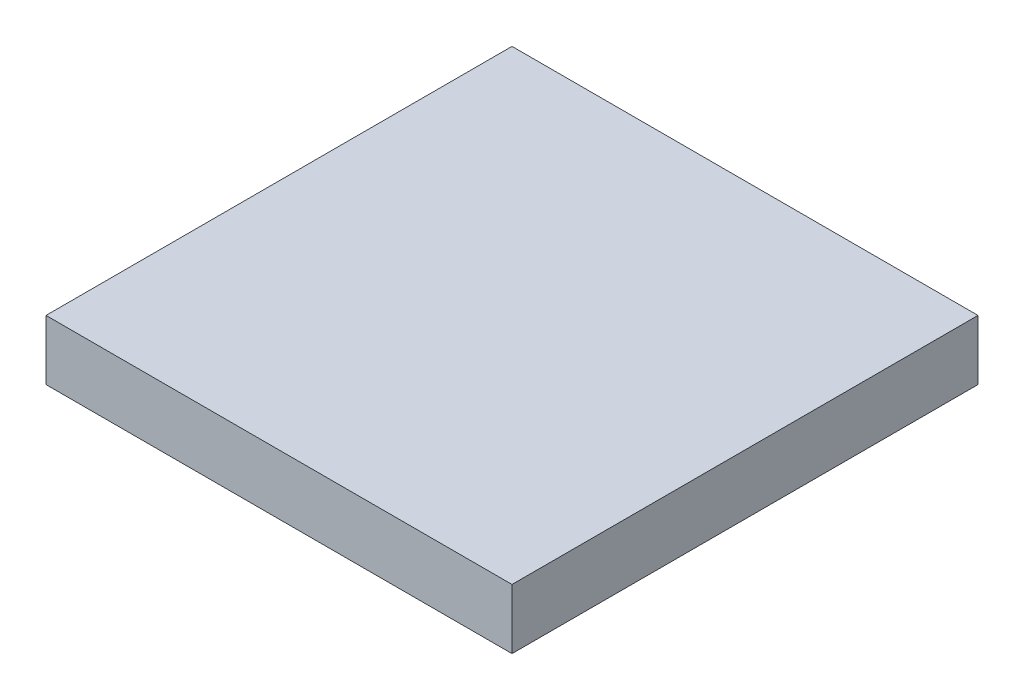
from build123d import *

# Parameters (mm, degrees)
BASES_W    = 7
BASES_H    = 7
BASE_DEPTH = 0.9


with BuildPart() as part:
    # BaseS → Base (new body)
    with BuildSketch(Plane(origin=(0, 0, 0), x_dir=(1, 0, 0), z_dir=(0, 1, 0))):
        Rectangle(BASES_W, BASES_H)
    extrude(amount=BASE_DEPTH)


solid = part.part
